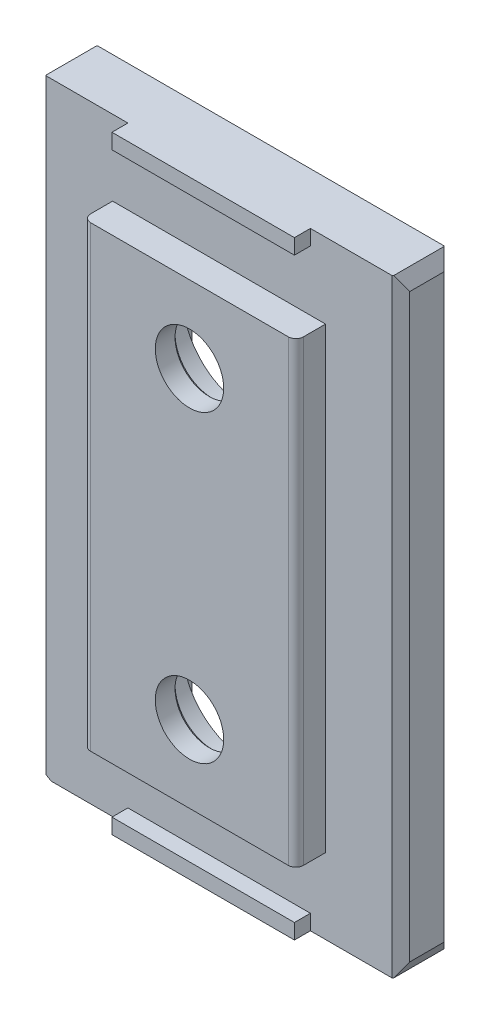
from build123d import *

# Parameters (mm, degrees)
SKETCH1_W                                        = 23.9
SKETCH1_H                                        = 40
BOSS_EXTRUDE1_DEPTH                              = 3.4
CUT_EXTRUDE1_DEPTH                               = 30
SKETCH3_W                                        = 14
SKETCH3_H                                        = 30.1
BOSS_EXTRUDE2_DEPTH                              = 1.95
SKETCH4_W                                        = 10.4
SKETCH4_H                                        = 30
CUT_EXTRUDE2_DEPTH                               = 1.55
CUT_EXTRUDE3_REACH                               = 2.95
SKETCH6_W                                        = 10.4
SKETCH6_H                                        = 1.75
CUT_EXTRUDE4_REACH                               = 2.95
SKETCH8_W                                        = 10.4
SKETCH8_H                                        = 1.75
SKETCH9_W                                        = 0.6
SKETCH9_H                                        = 30
CUT_EXTRUDE5_DEPTH                               = 1.8
SKETCH10_W                                       = 0.6
SKETCH10_H                                       = 30
CUT_EXTRUDE6_DEPTH                               = 1.8
SKETCH11_W                                       = 12
SKETCH11_H                                       = 1
BOSS_EXTRUDE3_DEPTH                              = 1.05
SKETCH12_W                                       = 12
SKETCH12_H                                       = 1
BOSS_EXTRUDE4_DEPTH                              = 1.05
CBORE_FOR_M4_HEX_HEAD_MACHINE_SCREW1_D           = 4.5
CBORE_FOR_M4_HEX_HEAD_MACHINE_SCREW1_DEPTH       = 3.8
CBORE_FOR_M4_HEX_HEAD_MACHINE_SCREW1_CBORE_D     = 8.5
CBORE_FOR_M4_HEX_HEAD_MACHINE_SCREW1_CBORE_DEPTH = 2.3
CHAMFER1_SIZE                                    = 0.527
CHAMFER1_SIZE2                                   = 0.913344887
CHAMFER1_PART_2_SIZE                             = 0.527
CHAMFER1_PART_2_SIZE2                            = 0.913344887
CHAMFER1_PART_3_SIZE                             = 0.527
CHAMFER1_PART_3_SIZE2                            = 0.913344887
CHAMFER2_SIZE                                    = 0.2
CHAMFER3_SIZE                                    = 0.577
CHAMFER4_SIZE                                    = 0.913344887
CHAMFER4_SIZE2                                   = 0.527
FILLET1_R                                        = 0.5


with BuildPart() as part:
    # Sketch1 → Boss-Extrude1 (new body)
    with BuildSketch(Plane.XY.offset(7.55)):
        Rectangle(SKETCH1_W, SKETCH1_H)
    extrude(amount=-BOSS_EXTRUDE1_DEPTH)

    # Sketch2 → Cut-Extrude1 (cut)
    with BuildSketch(Plane.XZ.offset(15)):
        with BuildLine():
            Line((7, 7.310697145), (7, 7.55))
            Line((7, 7.55), (6.995, 7.55))
            Line((6.995, 7.55), (6.995, 7.4))
            ThreePointArc((6.995, 7.4), (6.996250978, 7.35527864), (7, 7.310697145))
        make_face()
    extrude(amount=-CUT_EXTRUDE1_DEPTH, mode=Mode.SUBTRACT)

    # Sketch3 → Boss-Extrude2 (add)
    with BuildSketch(Plane.XY.offset(7.55)):
        with Locations((-0.005, 0)):
            Rectangle(SKETCH3_W, SKETCH3_H)
    extrude(amount=BOSS_EXTRUDE2_DEPTH)

    # Sketch4 → Cut-Extrude2 (cut)
    with BuildSketch(Plane(origin=(0, 0, 4.15), x_dir=(-1, 0, 0), z_dir=(0, 0, -1))):
        Rectangle(SKETCH4_W, SKETCH4_H)
    extrude(amount=-CUT_EXTRUDE2_DEPTH, mode=Mode.SUBTRACT)

    # Sketch6 → Cut-Extrude3 (cut, up to next)
    with BuildSketch(Plane.XY.offset(5.1), mode=Mode.PRIVATE) as cut_extrude3_sk1:
        with Locations((0, -15.875)):
            Rectangle(SKETCH6_W, SKETCH6_H)
    cut_extrude3_tool1 = extrude(cut_extrude3_sk1.sketch, amount=-CUT_EXTRUDE3_REACH, mode=Mode.PRIVATE) & part.part
    add(cut_extrude3_tool1.solids().sort_by_distance((0, -15.875, 5.1))[0], mode=Mode.SUBTRACT)

    # Sketch8 → Cut-Extrude4 (cut, up to next)
    with BuildSketch(Plane.XY.offset(5.1), mode=Mode.PRIVATE) as cut_extrude4_sk1:
        with Locations((0, 15.875)):
            Rectangle(SKETCH8_W, SKETCH8_H)
    cut_extrude4_tool1 = extrude(cut_extrude4_sk1.sketch, amount=-CUT_EXTRUDE4_REACH, mode=Mode.PRIVATE) & part.part
    add(cut_extrude4_tool1.solids().sort_by_distance((0, 15.875, 5.1))[0], mode=Mode.SUBTRACT)

    # Sketch9 → Cut-Extrude5 (cut)
    with BuildSketch(Plane(origin=(-5.2, 0, 0), x_dir=(0, 0, -1), z_dir=(1, 0, 0))):
        with Locations((-5.4, 0)):
            Rectangle(SKETCH9_W, SKETCH9_H)
    extrude(amount=-CUT_EXTRUDE5_DEPTH, mode=Mode.SUBTRACT)

    # Sketch10 → Cut-Extrude6 (cut)
    with BuildSketch(Plane.ZY.offset(-5.2)):
        with Locations((5.4, 0)):
            Rectangle(SKETCH10_W, SKETCH10_H)
    extrude(amount=-CUT_EXTRUDE6_DEPTH, mode=Mode.SUBTRACT)

    # Sketch11 → Boss-Extrude3 (add)
    with BuildSketch(Plane.XY.offset(7.55)):
        with Locations((0, 19.5)):
            Rectangle(SKETCH11_W, SKETCH11_H)
    extrude(amount=BOSS_EXTRUDE3_DEPTH)

    # Sketch12 → Boss-Extrude4 (add)
    with BuildSketch(Plane.XY.offset(7.55)):
        with Locations((0, -19.5)):
            Rectangle(SKETCH12_W, SKETCH12_H)
    extrude(amount=BOSS_EXTRUDE4_DEPTH)

    # CBORE for M4 Hex Head Machine Screw1
    with Locations(Plane(origin=(0, 0, 5.7), x_dir=(-1, 0, 0), z_dir=(0, 0, -1))):
        with Locations((0, 10), (0, -10)):
            CounterBoreHole(CBORE_FOR_M4_HEX_HEAD_MACHINE_SCREW1_D / 2, CBORE_FOR_M4_HEX_HEAD_MACHINE_SCREW1_CBORE_D / 2, CBORE_FOR_M4_HEX_HEAD_MACHINE_SCREW1_CBORE_DEPTH, depth=CBORE_FOR_M4_HEX_HEAD_MACHINE_SCREW1_DEPTH)

    # Chamfer1
    chamfer1_edges = [part.edges().sort_by_distance(p)[0] for p in [
        (-11.95, 20, 5.85),
    ]]
    chamfer1_side = [part.faces().sort_by_distance(p)[0] for p in [
        (0, 20, 6.148689538),
    ]]
    chamfer(chamfer1_edges, length=CHAMFER1_SIZE, length2=CHAMFER1_SIZE2, reference=chamfer1_side[0])

    # Chamfer1 part 2
    chamfer1_part_2_edges = [part.edges().sort_by_distance(p)[0] for p in [
        (11.95, -20, 5.85),
    ]]
    chamfer1_part_2_side = [part.faces().sort_by_distance(p)[0] for p in [
        (0, -20, 6.148689538),
    ]]
    chamfer(chamfer1_part_2_edges, length=CHAMFER1_PART_2_SIZE, length2=CHAMFER1_PART_2_SIZE2, reference=chamfer1_part_2_side[0])

    # Chamfer1 part 3
    chamfer1_part_3_edges = [part.edges().sort_by_distance(p)[0] for p in [
        (-11.95, -20, 5.85),
    ]]
    chamfer1_part_3_side = [part.faces().sort_by_distance(p)[0] for p in [
        (-11.95, 0, 5.85),
    ]]
    chamfer(chamfer1_part_3_edges, length=CHAMFER1_PART_3_SIZE, length2=CHAMFER1_PART_3_SIZE2, reference=chamfer1_part_3_side[0])

    # Chamfer2
    chamfer2_edges = [part.edges().sort_by_distance(p)[0] for p in [
        (-2.25, -10, 8),
        (-2.25, 10, 8),
    ]]
    chamfer(chamfer2_edges, length=CHAMFER2_SIZE)

    # Chamfer3
    chamfer3_edges = [part.edges().sort_by_distance(p)[0] for p in [
        (11.95, 0.456672444, 7.55),
        (11.95, 0.456672444, 4.15),
        (-11.95, -0.193172444, 4.15),
        (-11.95, -0.193172444, 7.55),
    ]]
    chamfer(chamfer3_edges, length=CHAMFER3_SIZE)

    # Chamfer4
    chamfer4_edges = [part.edges().sort_by_distance(p)[0] for p in [
        (11.95, 20, 5.85),
    ]]
    chamfer4_side = [part.faces().sort_by_distance(p)[0] for p in [
        (11.95, 0.456672444, 5.85),
    ]]
    chamfer(chamfer4_edges, length=CHAMFER4_SIZE, length2=CHAMFER4_SIZE2, reference=chamfer4_side[0])

    # Fillet1
    fillet1_edges = [part.edges().sort_by_distance(p)[0] for p in [
        (6.995, 0, 9.5),
        (-7.005, 0, 9.5),
    ]]
    fillet(fillet1_edges, radius=FILLET1_R)


solid = part.part
